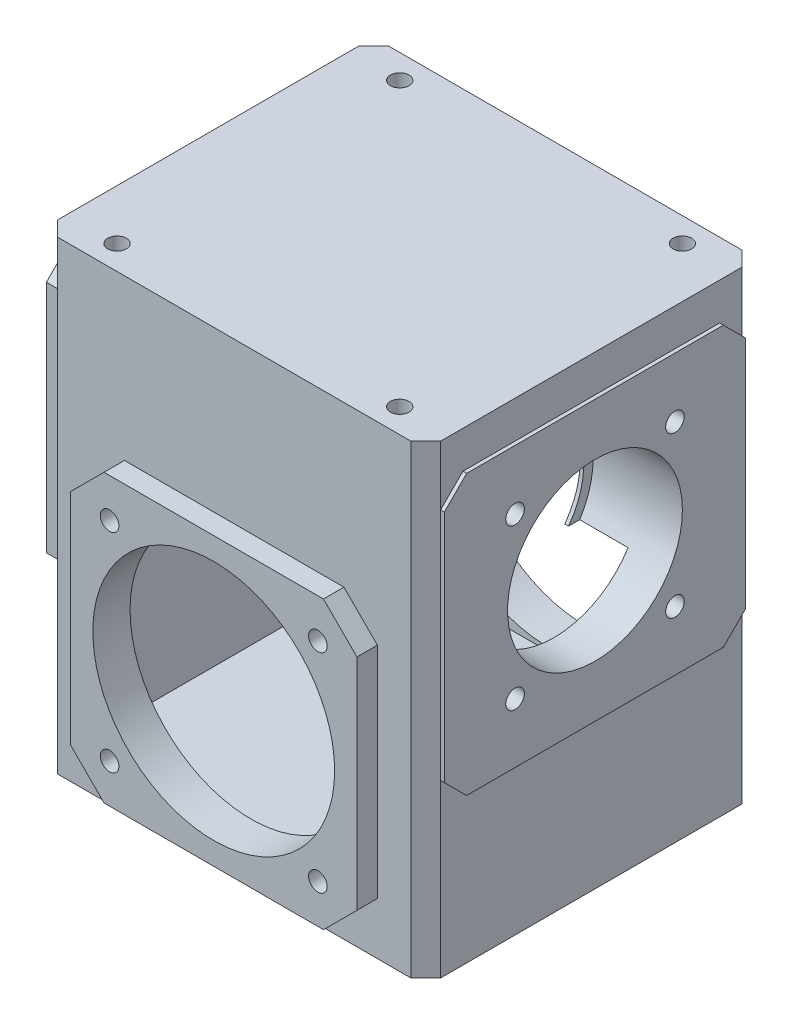
from build123d import *

# Parameters (mm, degrees)
EXTRUDE1_DEPTH             = 125
EXTRUDE2_DEPTH             = 5.5
EXTRUDE3_DEPTH             = 5.5
SKETCH4_R                  = 32.5
EXTRUDE5_DEPTH             = 101
EXTRUDE7_DEPTH             = 80
SKETCH7_R                  = 2.5
EXTRUDE9_DEPTH             = 15
LPATTERN1_COUNT            = 2
LPATTERN1_PITCH            = 56
LPATTERN2_COUNT            = 2
LPATTERN2_PITCH            = 56
LPATTERN2_COPY_1_SKETCH_R  = 2.5
LPATTERN2_COPY_1_DEPTH     = 15
EXTRUDE10_DEPTH            = 1
EXTRUDE11_DEPTH            = 3
SKETCH10_R                 = 23.5
EXTRUDE12_DEPTH            = 24
SKETCH11_R                 = 21
EXTRUDE13_DEPTH            = 84
SKETCH12_R                 = 23.5
EXTRUDE14_DEPTH            = 24
SKETCH13_R                 = 2.5
EXTRUDE15_DEPTH            = 20
LPATTERN3_COUNT            = 2
LPATTERN3_PITCH            = 43
LPATTERN4_COUNT            = 2
LPATTERN4_PITCH            = 43
LPATTERN4_COPY_1_SKETCH_R  = 2.5
LPATTERN4_COPY_1_DEPTH     = 20
SKETCH14_R                 = 2.5
EXTRUDE16_DEPTH            = 20
LPATTERN5_COUNT            = 2
LPATTERN5_PITCH            = 76
LPATTERN6_COUNT            = 2
LPATTERN6_PITCH            = 76
LPATTERN6_COPY_1_SKETCH_R  = 2.5
LPATTERN6_COPY_1_DEPTH     = 20
SKETCH15_R                 = 2.5
EXTRUDE17_DEPTH            = 20
LPATTERN7_COUNT            = 2
LPATTERN7_PITCH            = 76
LPATTERN8_COUNT            = 2
LPATTERN8_PITCH            = 76
LPATTERN8_COPY_1_SKETCH_R  = 2.5
LPATTERN8_COPY_1_DEPTH     = 20
SKETCH18_R                 = 2.5
EXTRUDE20_DEPTH            = 20
LPATTERN9_COUNT            = 2
LPATTERN9_PITCH            = 56
LPATTERN10_COUNT           = 2
LPATTERN10_PITCH           = 56
LPATTERN10_COPY_1_SKETCH_R = 2.5
LPATTERN10_COPY_1_DEPTH    = 20


with BuildPart() as part:
    # Sketch1 → Extrude1 (new body)
    with BuildSketch(Plane(origin=(0, 0, 0), x_dir=(1, 0, 0), z_dir=(0, 1, 0))):
        Polygon((0, 0), (0, 81), (4, 85), (99, 85), (103, 81), (103, 0), (99, -4), (4, -4), align=None)
    extrude(amount=EXTRUDE1_DEPTH)

    # Sketch2 → Extrude2 (add)
    with BuildSketch(Plane.XY.offset(4)):
        Polygon((22, 82), (81, 82), (90, 73), (90, 14), (81, 5), (22, 5), (13, 14), (13, 73), align=None)
    extrude(amount=EXTRUDE2_DEPTH)

    # Sketch3 → Extrude3 (add)
    with BuildSketch(Plane(origin=(0, 0, -85), x_dir=(-1, 0, 0), z_dir=(0, 0, -1))):
        Polygon((-81, 82), (-22, 82), (-13, 73), (-13, 14), (-22, 5), (-81, 5), (-90, 14), (-90, 73), align=None)
    extrude(amount=EXTRUDE3_DEPTH)

    # Sketch4 → Extrude5 (cut, through all)
    with BuildSketch(Plane.XY.offset(9.5)):
        with Locations((51.5, 43.5)):
            Circle(SKETCH4_R)
    extrude(amount=-EXTRUDE5_DEPTH, mode=Mode.SUBTRACT)

    # Sketch5 → Extrude7 (cut)
    with BuildSketch(Plane.XY.offset(-0.5)):
        Polygon((10, 10), (93, 10), (93, 65), (79, 65), (79, 110), (24, 110), (24, 65), (10, 65), align=None)
    extrude(amount=-EXTRUDE7_DEPTH, mode=Mode.SUBTRACT)

    # Sketch7 → Extrude9 (cut)
    with BuildSketch(Plane.XY.offset(9.5)):
        with Locations((23.5, 71.5)):
            Circle(SKETCH7_R)
    extrude9 = extrude(amount=-EXTRUDE9_DEPTH, mode=Mode.SUBTRACT)

    # LPattern1: Extrude9 ×2
    with Locations(*[(i * LPATTERN1_PITCH, 0, 0) for i in range(1, LPATTERN1_COUNT)]):
        add(extrude9, mode=Mode.SUBTRACT)

    # LPattern2: Extrude9 ×2
    with Locations(*[(0, -i * LPATTERN2_PITCH, 0) for i in range(1, LPATTERN2_COUNT)]):
        add(extrude9, mode=Mode.SUBTRACT)

    # LPattern2 copy 1 sketch → LPattern2 copy 1 (cut)
    with BuildSketch(Plane(origin=(56, -56, 9.5), x_dir=(1, 0, 0), z_dir=(0, 0, 1))):
        with Locations((23.5, 71.5)):
            Circle(LPATTERN2_COPY_1_SKETCH_R)
    extrude(amount=-LPATTERN2_COPY_1_DEPTH, mode=Mode.SUBTRACT)

    # Sketch8 → Extrude10 (add)
    with BuildSketch(Plane(origin=(103, 0, 0), x_dir=(0, 0, -1), z_dir=(1, 0, 0))):
        Polygon((6, 115), (75, 115), (81, 109), (81, 46), (75, 40), (6, 40), (0, 46), (0, 109), align=None)
    extrude(amount=EXTRUDE10_DEPTH)

    # Sketch9 → Extrude11 (add)
    with BuildSketch(Plane.ZY):
        Polygon((-75, 115), (-6, 115), (0, 109), (0, 46), (-6, 40), (-75, 40), (-81, 46), (-81, 109), align=None)
    extrude(amount=EXTRUDE11_DEPTH)

    # Sketch10 → Extrude12 (cut)
    with BuildSketch(Plane(origin=(104, 0, 0), x_dir=(0, 0, -1), z_dir=(1, 0, 0))):
        with Locations((40.5, 77.5)):
            Circle(SKETCH10_R)
    extrude(amount=-EXTRUDE12_DEPTH, mode=Mode.SUBTRACT)

    # Sketch11 → Extrude13 (cut, through all)
    with BuildSketch(Plane(origin=(80, 0, 0), x_dir=(0, 0, -1), z_dir=(1, 0, 0))):
        with Locations((40.5, 77.5)):
            Circle(SKETCH11_R)
    extrude(amount=-EXTRUDE13_DEPTH, mode=Mode.SUBTRACT)

    # Sketch12 → Extrude14 (cut)
    with BuildSketch(Plane.ZY.offset(3)):
        with Locations((-40.5, 77.5)):
            Circle(SKETCH12_R)
    extrude(amount=-EXTRUDE14_DEPTH, mode=Mode.SUBTRACT)

    # Sketch13 → Extrude15 (cut)
    with BuildSketch(Plane(origin=(104, 0, 0), x_dir=(0, 0, -1), z_dir=(1, 0, 0))):
        with Locations((19, 99)):
            Circle(SKETCH13_R)
    extrude15 = extrude(amount=-EXTRUDE15_DEPTH, mode=Mode.SUBTRACT)

    # LPattern3: Extrude15 ×2
    with Locations(*[(0, 0, -i * LPATTERN3_PITCH) for i in range(1, LPATTERN3_COUNT)]):
        add(extrude15, mode=Mode.SUBTRACT)

    # LPattern4: Extrude15 ×2
    with Locations(*[(0, -i * LPATTERN4_PITCH, 0) for i in range(1, LPATTERN4_COUNT)]):
        add(extrude15, mode=Mode.SUBTRACT)

    # LPattern4 copy 1 sketch → LPattern4 copy 1 (cut)
    with BuildSketch(Plane(origin=(104, -43, -43), x_dir=(0, 0, -1), z_dir=(1, 0, 0))):
        with Locations((19, 99)):
            Circle(LPATTERN4_COPY_1_SKETCH_R)
    extrude(amount=-LPATTERN4_COPY_1_DEPTH, mode=Mode.SUBTRACT)

    # Sketch14 → Extrude16 (cut)
    with BuildSketch(Plane(origin=(0, 125, 0), x_dir=(1, 0, 0), z_dir=(0, 1, 0))):
        with Locations((13.5, 78.5)):
            Circle(SKETCH14_R)
    extrude16 = extrude(amount=-EXTRUDE16_DEPTH, mode=Mode.SUBTRACT)

    # LPattern5: Extrude16 ×2
    with Locations(*[(i * LPATTERN5_PITCH, 0, 0) for i in range(1, LPATTERN5_COUNT)]):
        add(extrude16, mode=Mode.SUBTRACT)

    # LPattern6: Extrude16 ×2
    with Locations(*[(0, 0, i * LPATTERN6_PITCH) for i in range(1, LPATTERN6_COUNT)]):
        add(extrude16, mode=Mode.SUBTRACT)

    # LPattern6 copy 1 sketch → LPattern6 copy 1 (cut)
    with BuildSketch(Plane(origin=(76, 125, 76), x_dir=(1, 0, 0), z_dir=(0, 1, 0))):
        with Locations((13.5, 78.5)):
            Circle(LPATTERN6_COPY_1_SKETCH_R)
    extrude(amount=-LPATTERN6_COPY_1_DEPTH, mode=Mode.SUBTRACT)

    # Sketch15 → Extrude17 (cut)
    with BuildSketch(Plane.XZ):
        with Locations((13.5, -2.5)):
            Circle(SKETCH15_R)
    extrude17 = extrude(amount=-EXTRUDE17_DEPTH, mode=Mode.SUBTRACT)

    # LPattern7: Extrude17 ×2
    with Locations(*[(i * LPATTERN7_PITCH, 0, 0) for i in range(1, LPATTERN7_COUNT)]):
        add(extrude17, mode=Mode.SUBTRACT)

    # LPattern8: Extrude17 ×2
    with Locations(*[(0, 0, -i * LPATTERN8_PITCH) for i in range(1, LPATTERN8_COUNT)]):
        add(extrude17, mode=Mode.SUBTRACT)

    # LPattern8 copy 1 sketch → LPattern8 copy 1 (cut)
    with BuildSketch(Plane(origin=(76, 0, -76), x_dir=(1, 0, 0), z_dir=(0, -1, 0))):
        with Locations((13.5, -2.5)):
            Circle(LPATTERN8_COPY_1_SKETCH_R)
    extrude(amount=-LPATTERN8_COPY_1_DEPTH, mode=Mode.SUBTRACT)

    # Sketch18 → Extrude20 (cut)
    with BuildSketch(Plane(origin=(0, 0, -90.5), x_dir=(-1, 0, 0), z_dir=(0, 0, -1))):
        with Locations((-79.5, 71.5)):
            Circle(SKETCH18_R)
    extrude20 = extrude(amount=-EXTRUDE20_DEPTH, mode=Mode.SUBTRACT)

    # LPattern9: Extrude20 ×2
    with Locations(*[(-i * LPATTERN9_PITCH, 0, 0) for i in range(1, LPATTERN9_COUNT)]):
        add(extrude20, mode=Mode.SUBTRACT)

    # LPattern10: Extrude20 ×2
    with Locations(*[(0, -i * LPATTERN10_PITCH, 0) for i in range(1, LPATTERN10_COUNT)]):
        add(extrude20, mode=Mode.SUBTRACT)

    # LPattern10 copy 1 sketch → LPattern10 copy 1 (cut)
    with BuildSketch(Plane(origin=(-56, -56, -90.5), x_dir=(-1, 0, 0), z_dir=(0, 0, -1))):
        with Locations((-79.5, 71.5)):
            Circle(LPATTERN10_COPY_1_SKETCH_R)
    extrude(amount=-LPATTERN10_COPY_1_DEPTH, mode=Mode.SUBTRACT)


solid = part.part
